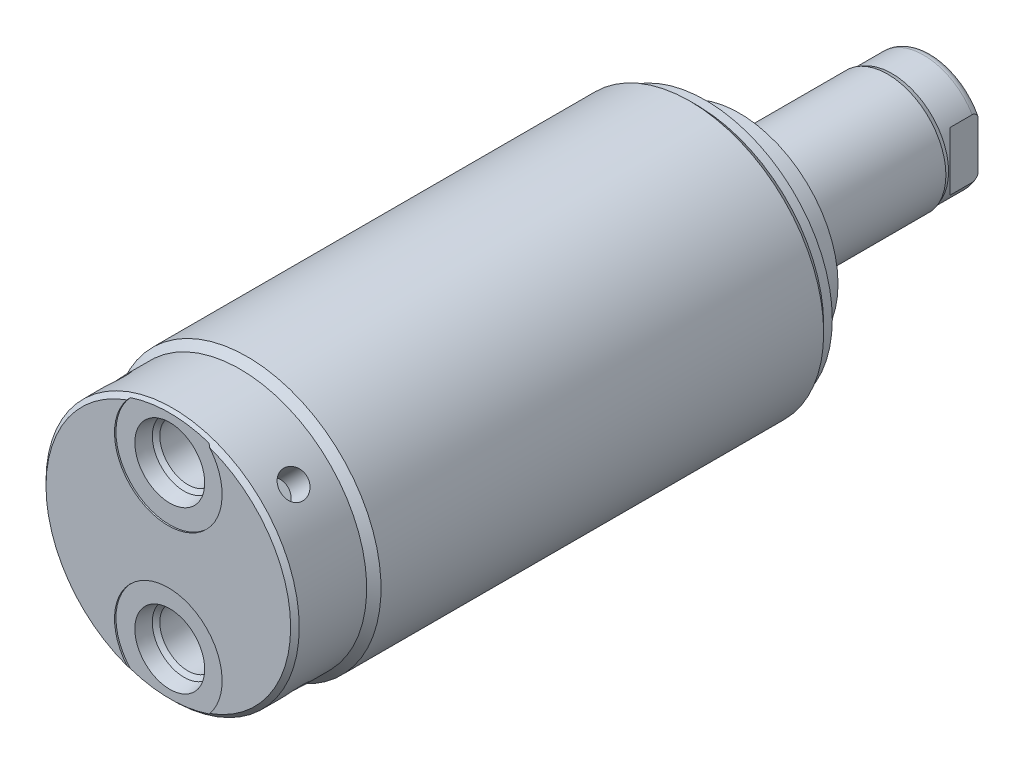
from build123d import *

# Parameters (mm, degrees)
SKETCH1_R          = 23.6855
EXTRUDE1_DEPTH     = 95.123
CHAMFER1_SIZE      = 0.762
SKETCH6_R          = 17.4625
EXTRUDE2_DEPTH     = 5.969
SKETCH7_W          = 33.655
SKETCH7_H          = 10.31875
CUT_EXTRUDE4_DEPTH = 19.84248
HOLE1_D            = 4.7498
HOLE1_DEPTH        = 4.7498
CIRPATTERN1_COUNT  = 4
LPATTERN1_COUNT    = 2
LPATTERN1_PITCH    = 28.5496


with BuildPart() as part:
    # Sketch1 → Extrude1 (new body)
    with BuildSketch(Plane.XY):
        Circle(SKETCH1_R)
    extrude(amount=EXTRUDE1_DEPTH)

    # Sketch2 → Cut-Revolve1 (revolve, cut)
    with BuildSketch(Plane(origin=(0, 0, 0), x_dir=(1, 0, 0), z_dir=(0, 1, 0)), mode=Mode.PRIVATE) as cut_revolve1_sk:
        Polygon((23.6855, -95.123), (23.6855, -81.153), (22.4155, -82.423), (22.4155, -95.123), align=None)
    revolve(cut_revolve1_sk.sketch.rotate(Axis((0, 0, 0), (0, 0, 1)), 180), axis=Axis((0, 0, 0), (0, 0, 1)), mode=Mode.SUBTRACT)  # turned: the seam where the file's is

    # Sketch3 → Cut-Revolve2 (revolve, cut)
    with BuildSketch(Plane(origin=(0, 0, 0), x_dir=(1, 0, 0), z_dir=(0, 1, 0)), mode=Mode.PRIVATE) as cut_revolve2_sk:
        Polygon((22.4155, 0), (22.4155, -1.524), (23.6855, -2.794), (23.6855, 0), align=None)
    revolve(cut_revolve2_sk.sketch.rotate(Axis((0, 0, 0), (0, 0, -1)), 180), axis=Axis((0, 0, 0), (0, 0, -1)), mode=Mode.SUBTRACT)  # turned: the seam where the file's is

    # Chamfer1
    chamfer1_edges = [part.edges().sort_by_distance(p)[0] for p in [
        (22.4155, 0, 95.123),
    ]]
    chamfer(chamfer1_edges, length=CHAMFER1_SIZE)

    # S2D0002 → Cut-Revolve3 (revolve, cut)
    with BuildSketch(Plane(origin=(0, 0, 0), x_dir=(0, -1, 0), z_dir=(1, 0, 0)), mode=Mode.PRIVATE) as cut_revolve3_sk:
        Polygon((20.4597, -94.869), (23.7998, -94.869), (23.7998, -95.123), (14.2748, -95.123), (14.2748, -80.899), (19.2532, -80.899), (19.2532, -91.652393135), (19.917106865, -92.3163), align=None)
    cut_revolve3 = revolve(cut_revolve3_sk.sketch.rotate(Axis((0, -14.2748, 14.6685), (0, 0, -1)), 270), axis=Axis((0, -14.2748, 14.6685), (0, 0, -1)), mode=Mode.SUBTRACT)  # turned: the seam where the file's is

    # Sketch6 → Extrude2 (add)
    with BuildSketch(Plane(origin=(0, 0, 0), x_dir=(-1, 0, 0), z_dir=(0, 0, -1))):
        with Locations(Location((0, 0, 0), (0, 0, 180))):  # turned: the seam where the file's is
            Circle(SKETCH6_R)
    extrude(amount=EXTRUDE2_DEPTH)

    # Sketch7 → Revolve1 (revolve)
    with BuildSketch(Plane(origin=(0, 0, 0), x_dir=(0, 0, -1), z_dir=(1, 0, 0)), mode=Mode.PRIVATE) as revolve1_sk:
        with Locations((22.7965, -5.159375)):
            Rectangle(SKETCH7_W, SKETCH7_H)
    revolve(revolve1_sk.sketch.rotate(Axis((0, 0, 0), (0, 0, -1)), 90), axis=Axis((0, 0, 0), (0, 0, -1)))  # turned: the seam where the file's is

    # S2D0001 → Cut-Revolve5 (revolve, cut)
    with BuildSketch(Plane(origin=(0, 0, 0), x_dir=(1, 0, 0), z_dir=(0, 1, 0))):
        Polygon((3.2639, 37.688260017), (3.2639, 24.5618), (0, 24.5618), (0, 39.624), (4.3815, 39.624), align=None)
    revolve(axis=Axis((0, 0, 31.308359971), (0, 0, -1)), mode=Mode.SUBTRACT)

    # Sketch9 → Cut-Revolve6 (revolve, cut)
    with BuildSketch(Plane(origin=(0, 0, 0), x_dir=(0, -1, 0), z_dir=(1, 0, 0)), mode=Mode.PRIVATE) as cut_revolve6_sk:
        with BuildLine():
            Line((-10.31875, 32.2072), (-10.033, 32.9692))
            Line((-10.033, 32.9692), (-10.033, 38.608))
            ThreePointArc((-10.033, 38.608), (-9.932678675, 39.151796865), (-9.644922533, 39.624))
            Line((-9.644922533, 39.624), (-10.31875, 39.624))
            Line((-10.31875, 39.624), (-10.31875, 32.2072))
        make_face()
    revolve(cut_revolve6_sk.sketch.rotate(Axis((0, 0, -12.65936), (0, 0, -1)), 90), axis=Axis((0, 0, -12.65936), (0, 0, -1)), mode=Mode.SUBTRACT)  # turned: the seam where the file's is

    # Sketch13 → Cut-Extrude4 (cut, symmetric)
    with BuildSketch(Plane(origin=(0, 0, 0), x_dir=(1, 0, 0), z_dir=(0, 1, 0))):
        Polygon((8.5852, 39.624), (8.5852, 34.671), (10.033, 33.2232), (10.033, 39.624), align=None)
        Polygon((-8.5852, 39.624), (-8.5852, 34.671), (-10.033, 33.2232), (-10.033, 39.624), align=None)
    extrude(amount=CUT_EXTRUDE4_DEPTH, both=True, mode=Mode.SUBTRACT)

    # Hole1
    with Locations(Plane(origin=(-15.850152054, 15.850152054, 88.773), x_dir=(0.707106781, 0.707106781, 0), z_dir=(-0.707106781, 0.707106781, 0))):
        with Locations((0, 0)):
            hole1 = Hole(HOLE1_D / 2, depth=HOLE1_DEPTH)

    # CirPattern1: Hole1 ×4 about axis
    cirpattern1_axis = Axis((0, 0, 0), (0, 0, 1))
    for i in range(1, CIRPATTERN1_COUNT):
        add(hole1.rotate(cirpattern1_axis, i * 360 / CIRPATTERN1_COUNT), mode=Mode.SUBTRACT)

    # LPattern1: Cut-Revolve3 ×2
    with Locations(*[(0, i * LPATTERN1_PITCH, 0) for i in range(1, LPATTERN1_COUNT)]):
        add(cut_revolve3, mode=Mode.SUBTRACT)


solid = part.part
